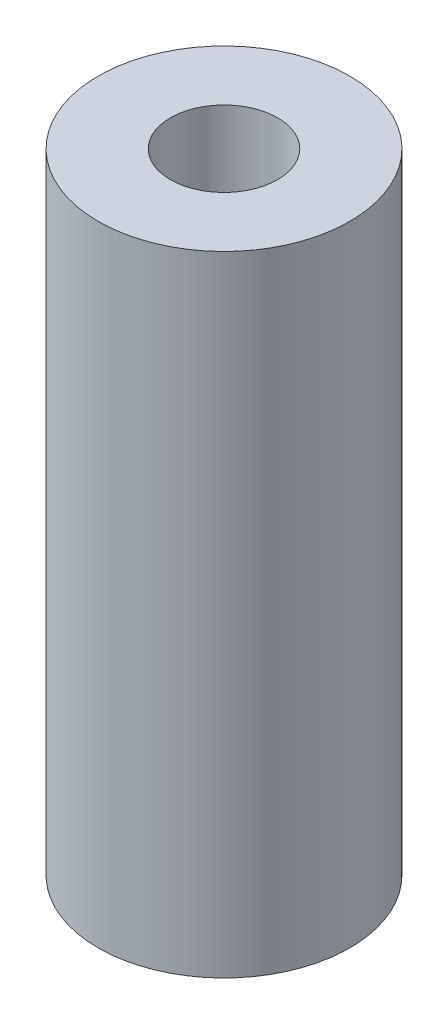
from build123d import *

# Parameters (mm, degrees)
SKETCH1_R      = 3.175
SKETCH1_R_2    = 1.35255
EXTRUDE1_DEPTH = 15.875


with BuildPart() as part:
    # Sketch1 → Extrude1 (new body)
    with BuildSketch(Plane(origin=(0, 0, 0), x_dir=(1, 0, 0), z_dir=(0, 1, 0))):
        Circle(SKETCH1_R)
        Circle(SKETCH1_R_2, mode=Mode.SUBTRACT)
    extrude(amount=EXTRUDE1_DEPTH)


solid = part.part
